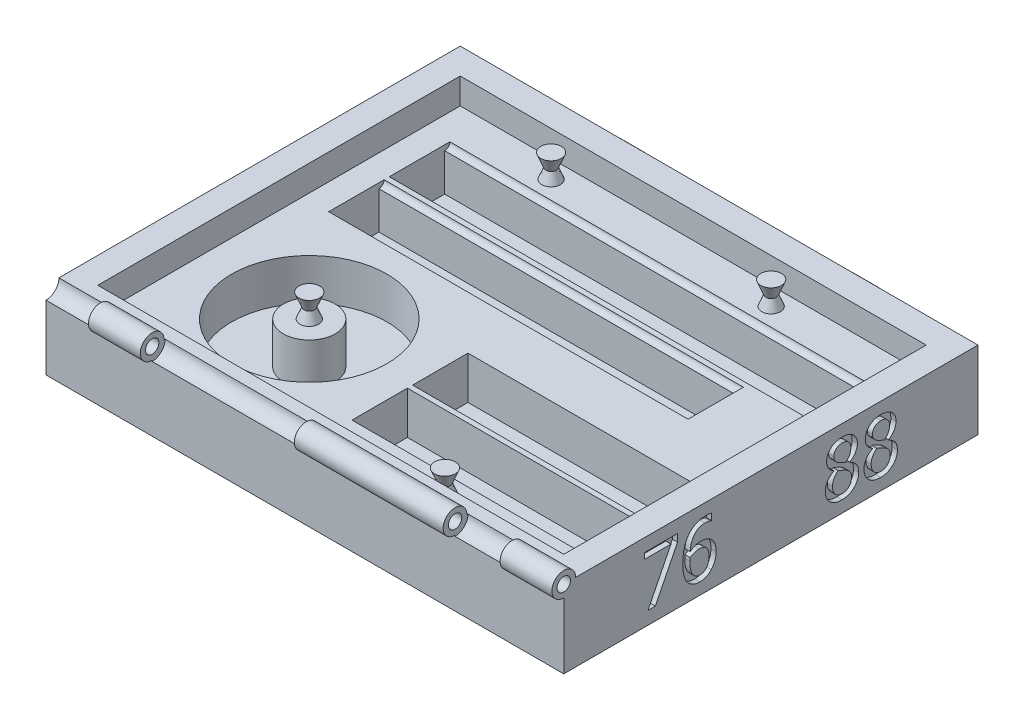
from build123d import *

# Parameters (mm, degrees)
BOSS_EXTRUDE1_DEPTH      = 177.8
SKETCH2_W                = 203.2
SKETCH2_H                = 27.178
SKETCH2_W_2              = 176.276
SKETCH2_H_2              = 24.638
SKETCH2_W_3              = 108.966
CUT_EXTRUDE1_DEPTH       = 12.7
SKETCH3_R                = 3.81
CUT_EXTRUDE2_DEPTH       = 108.966
SKETCH4_R                = 3.81
CUT_EXTRUDE3_DEPTH       = 203.2
SKETCH5_R                = 3.81
CUT_EXTRUDE4_DEPTH       = 176.276
SKETCH6_W                = 108.966
SKETCH6_H                = 24.638
CUT_EXTRUDE5_DEPTH       = 8.255
SKETCH9_W                = 3.81
SKETCH9_H                = 3.81
BOSS_EXTRUDE2_DEPTH      = 211.328
SKETCH10_R               = 2.54
CUT_EXTRUDE6_DEPTH       = 108.966
SKETCH11_R               = 2.54
CUT_EXTRUDE7_DEPTH       = 108.966
SKETCH12_R               = 2.54
CUT_EXTRUDE8_DEPTH       = 176.276
SKETCH13_R               = 2.54
CUT_EXTRUDE9_DEPTH       = 203.2
SKETCH14_W               = 108.966
SKETCH14_H               = 24.638
SKETCH14_W_2             = 176.276
SKETCH14_W_3             = 203.2
SKETCH14_H_2             = 27.178
CUT_EXTRUDE10_DEPTH      = 8.255
SKETCH15_W               = 12.7
SKETCH15_H               = 50.8
CUT_EXTRUDE11_DEPTH      = 44.45
CUT_EXTRUDE11_DEPTH_BACK = 379.73
SKETCH16_W               = 12.7
SKETCH16_H               = 50.8
BOSS_EXTRUDE3_DEPTH      = 254
SKETCH17_W               = 12.7
SKETCH17_H               = 50.8
BOSS_EXTRUDE4_DEPTH      = 254
SKETCH18_W               = 203.2
SKETCH18_H               = 12.7
CUT_EXTRUDE12_DEPTH      = 254
CUT_EXTRUDE13_DEPTH      = 2.54
SKETCH26_R               = 6.35
CUT_EXTRUDE14_DEPTH      = 309.626
SKETCH27_R               = 3.302
BOSS_EXTRUDE7_DEPTH      = 25.4
SKETCH29_R               = 5.842
SKETCH29_R_2             = 3.302
BOSS_EXTRUDE8_DEPTH      = 73.025
SKETCH31_R               = 5.842
SKETCH31_R_2             = 3.302
BOSS_EXTRUDE9_DEPTH      = 25.4
SKETCH35_R               = 38.1
CUT_EXTRUDE15_DEPTH      = 20.32
SKETCH36_R               = 12.7
BOSS_EXTRUDE11_DEPTH     = 20.32
SKETCH39_R               = 2.54
BOSS_EXTRUDE12_DEPTH     = 5.08
SKETCH47_R               = 2.54
BOSS_EXTRUDE13_DEPTH     = 5.08
SKETCH49_R               = 6.35
BOSS_EXTRUDE14_DEPTH     = 12.7
SKETCH51_R               = 6.35
BOSS_EXTRUDE15_DEPTH     = 12.7
SKETCH52_R               = 3.81
CUT_EXTRUDE16_DEPTH      = 137.16
FILLET1_R                = 5.08


with BuildPart() as part:
    # Sketch1 → Boss-Extrude1 (new body)
    with BuildSketch(Plane.XY):
        Polygon((0, 0), (254, 0), (254, 101.6), (241.3, 101.6), (241.3, 25.4), (12.7, 25.4), (12.7, 101.6), (0, 101.6), align=None)
    extrude(amount=BOSS_EXTRUDE1_DEPTH)

    # Sketch2 → Cut-Extrude1 (cut)
    with BuildSketch(Plane(origin=(0, 25.4, 0), x_dir=(1, 0, 0), z_dir=(0, 1, 0))):
        with Locations((127, -33.909)):
            Rectangle(SKETCH2_W, SKETCH2_H)
        with Locations((113.538, -64.897)):
            Rectangle(SKETCH2_W_2, SKETCH2_H_2)
        with Locations((174.117, -115.443)):
            Rectangle(SKETCH2_W_3, SKETCH2_H_2)
        with Locations((174.117, -145.161)):
            Rectangle(SKETCH2_W_3, SKETCH2_H_2)
    extrude(amount=-CUT_EXTRUDE1_DEPTH, mode=Mode.SUBTRACT)

    # Sketch3 → Cut-Extrude2 (cut)
    with BuildSketch(Plane.ZY.offset(-228.6)):
        with Locations((157.48, 25.4)):
            Circle(SKETCH3_R)
        with Locations((127.762, 25.4)):
            Circle(SKETCH3_R)
    extrude(amount=CUT_EXTRUDE2_DEPTH, mode=Mode.SUBTRACT)

    # Sketch4 → Cut-Extrude3 (cut)
    with BuildSketch(Plane.ZY.offset(-228.6)):
        with Locations((20.32, 25.4)):
            Circle(SKETCH4_R)
    extrude(amount=CUT_EXTRUDE3_DEPTH, mode=Mode.SUBTRACT)

    # Sketch5 → Cut-Extrude4 (cut)
    with BuildSketch(Plane.ZY.offset(-201.676)):
        with Locations((52.578, 25.4)):
            Circle(SKETCH5_R)
    extrude(amount=CUT_EXTRUDE4_DEPTH, mode=Mode.SUBTRACT)

    # Sketch6 → Cut-Extrude5 (cut)
    with BuildSketch(Plane(origin=(0, 12.7, 0), x_dir=(1, 0, 0), z_dir=(0, 1, 0))):
        with Locations((174.117, -145.161)):
            Rectangle(SKETCH6_W, SKETCH6_H)
    extrude(amount=-CUT_EXTRUDE5_DEPTH, mode=Mode.SUBTRACT)

    # Sketch9 → Boss-Extrude2 (add)
    with BuildSketch(Plane.ZY.offset(-228.6)):
        with Locations((159.385, 23.495)):
            Rectangle(SKETCH9_W, SKETCH9_H)
        with Locations((129.667, 23.495)):
            Rectangle(SKETCH9_W, SKETCH9_H)
        with Locations((50.673, 23.495)):
            Rectangle(SKETCH9_W, SKETCH9_H)
        with Locations((18.415, 23.495)):
            Rectangle(SKETCH9_W, SKETCH9_H)
    extrude(amount=BOSS_EXTRUDE2_DEPTH)

    # Sketch10 → Cut-Extrude6 (cut)
    with BuildSketch(Plane.ZY.offset(-228.6)):
        with Locations((157.48, 25.4)):
            Circle(SKETCH10_R)
    extrude(amount=CUT_EXTRUDE6_DEPTH, mode=Mode.SUBTRACT)

    # Sketch11 → Cut-Extrude7 (cut)
    with BuildSketch(Plane.ZY.offset(-228.6)):
        with Locations((127.762, 25.4)):
            Circle(SKETCH11_R)
    extrude(amount=CUT_EXTRUDE7_DEPTH, mode=Mode.SUBTRACT)

    # Sketch12 → Cut-Extrude8 (cut)
    with BuildSketch(Plane.ZY.offset(-201.676)):
        with Locations((52.578, 25.4)):
            Circle(SKETCH12_R)
    extrude(amount=CUT_EXTRUDE8_DEPTH, mode=Mode.SUBTRACT)

    # Sketch13 → Cut-Extrude9 (cut)
    with BuildSketch(Plane.ZY.offset(-228.6)):
        with Locations((20.32, 25.4)):
            Circle(SKETCH13_R)
    extrude(amount=CUT_EXTRUDE9_DEPTH, mode=Mode.SUBTRACT)

    # Sketch14 → Cut-Extrude10 (cut)
    with BuildSketch(Plane(origin=(0, 12.7, 0), x_dir=(1, 0, 0), z_dir=(0, 1, 0))):
        with Locations((174.117, -115.443)):
            Rectangle(SKETCH14_W, SKETCH14_H)
        with Locations((113.538, -64.897)):
            Rectangle(SKETCH14_W_2, SKETCH14_H)
        with Locations((127, -33.909)):
            Rectangle(SKETCH14_W_3, SKETCH14_H_2)
    extrude(amount=-CUT_EXTRUDE10_DEPTH, mode=Mode.SUBTRACT)

    # Sketch15 → Cut-Extrude11 (cut, two sides)
    with BuildSketch(Plane.XY.offset(177.8)) as cut_extrude11_sk:
        Polygon((12.7, 101.6), (12.7, 50.8), (241.3, 50.8), (241.3, 101.6), (254, 101.6), (254, 50.8), (294.328794801, 50.8), (294.328794801, 124.526428044), (-40.622984907, 124.526428044), (-40.622984907, 50.8), (0, 50.8), (0, 101.6), align=None)
        with Locations((6.35, 76.2)):
            Rectangle(SKETCH15_W, SKETCH15_H)
        with Locations((247.65, 76.2)):
            Rectangle(SKETCH15_W, SKETCH15_H)
    extrude(amount=CUT_EXTRUDE11_DEPTH, mode=Mode.SUBTRACT)
    extrude(cut_extrude11_sk.sketch, amount=-CUT_EXTRUDE11_DEPTH_BACK, mode=Mode.SUBTRACT)

    # Sketch16 → Boss-Extrude3 (add)
    with BuildSketch(Plane(origin=(254, 0, 0), x_dir=(0, 0, -1), z_dir=(1, 0, 0))):
        with Locations((-184.15, 25.4)):
            Rectangle(SKETCH16_W, SKETCH16_H)
    extrude(amount=-BOSS_EXTRUDE3_DEPTH)

    # Sketch17 → Boss-Extrude4 (add)
    with BuildSketch(Plane(origin=(254, 0, 0), x_dir=(0, 0, -1), z_dir=(1, 0, 0))):
        with Locations((6.35, 25.4)):
            Rectangle(SKETCH17_W, SKETCH17_H)
    extrude(amount=-BOSS_EXTRUDE4_DEPTH)

    # Sketch18 → Cut-Extrude12 (cut)
    with BuildSketch(Plane(origin=(254, 0, 0), x_dir=(0, 0, -1), z_dir=(1, 0, 0))):
        with Locations((-88.9, 44.45)):
            Rectangle(SKETCH18_W, SKETCH18_H)
    extrude(amount=-CUT_EXTRUDE12_DEPTH, mode=Mode.SUBTRACT)

    # Sketch25 → Cut-Extrude13 (cut)
    with BuildSketch(Plane(origin=(254, 0, 0), x_dir=(0, 0, -1), z_dir=(1, 0, 0))):
        Polygon((-134.716455696, 28.032436709), (-145.582792722, 6.35), (-149.184810127, 6.35), (-137.906526899, 28.856329114), (-150.792405063, 28.856329114), (-150.792405063, 31.75), (-134.716455696, 31.75), align=None)
        with BuildLine():
            add(Edge.make_bspline(
                [(-115.746835443, 14.62409019), (-115.754265987, 14.2971689), (-115.768836879, 13.656094076), (-115.892460294, 12.71225022), (-116.097444321, 11.809364679), (-116.380894986, 10.9501335), (-116.720897419, 10.142943973), (-117.134516856, 9.407605575), (-117.585891651, 8.728623869), (-117.94542237, 8.333616999), (-118.123061709, 8.138449367)],
                knots=[0, 0, 0, 0, 0.000980452, 0.001922613, 0.002850047, 0.003753998, 0.004633969, 0.005472752, 0.006282338, 0.007072998, 0.007072998, 0.007072998, 0.007072998], degree=3))
            add(Edge.make_bspline(
                [(-118.123061709, 8.138449367), (-118.313492965, 7.946720583), (-118.690582724, 7.567061475), (-119.316466328, 7.076861244), (-119.974186002, 6.656218321), (-120.663965914, 6.305547078), (-121.391827808, 6.040407142), (-122.154005881, 5.847491055), (-122.952283316, 5.730593007), (-123.498068702, 5.71491183), (-123.774762658, 5.706962025)],
                knots=[0, 0, 0, 0, 0.000810053, 0.001604057, 0.002378902, 0.003149517, 0.003920378, 0.004697743, 0.005504831, 0.006334721, 0.006334721, 0.006334721, 0.006334721], degree=3))
            add(Edge.make_bspline(
                [(-123.774762658, 5.706962025), (-124.054846776, 5.712776355), (-124.602242402, 5.724139863), (-125.404111023, 5.841004275), (-126.168078478, 6.017056739), (-126.892880073, 6.275237829), (-127.572508988, 6.610199113), (-128.216589464, 7.008340862), (-128.818572726, 7.482094043), (-129.179030779, 7.848049207), (-129.361155063, 8.032950949)],
                knots=[0, 0, 0, 0, 0.0008397, 0.001641108, 0.00242584, 0.003188555, 0.00394347, 0.00469485, 0.005456688, 0.006234718, 0.006234718, 0.006234718, 0.006234718], degree=3))
            add(Edge.make_bspline(
                [(-129.361155063, 8.032950949), (-129.573854928, 8.280724977), (-130.010793532, 8.789714663), (-130.554498534, 9.675944215), (-131.025026034, 10.675272197), (-131.361321511, 11.585407386), (-131.582854659, 12.375147016), (-131.733331863, 13.010356591), (-131.866602572, 13.678161633), (-131.962641653, 14.381626275), (-132.043769901, 15.116977219), (-132.104274503, 15.885884522), (-132.139865466, 16.690174248), (-132.14280382, 17.238069973), (-132.144303797, 17.517761076)],
                knots=[0, 0, 0, 0, 0.000978404, 0.002009885, 0.003106453, 0.004288921, 0.004915499, 0.005566184, 0.006246988, 0.006957452, 0.007695308, 0.0084663, 0.009270866, 0.01010989, 0.01010989, 0.01010989, 0.01010989], degree=3))
            add(Edge.make_bspline(
                [(-132.144303797, 17.517761076), (-132.138186193, 18.062331069), (-132.126252123, 19.124664563), (-131.986882078, 20.677021482), (-131.789888669, 22.150324887), (-131.492837148, 23.542673457), (-131.107694662, 24.849971548), (-130.635700427, 26.073962328), (-130.070741737, 27.211486195), (-129.615796388, 27.909189771), (-129.391297468, 28.253481013)],
                knots=[0, 0, 0, 0, 0.001633208, 0.003186022, 0.004672317, 0.006090194, 0.007452442, 0.008756679, 0.010021563, 0.011253802, 0.011253802, 0.011253802, 0.011253802], degree=3))
            add(Edge.make_bspline(
                [(-129.391297468, 28.253481013), (-129.1542525, 28.566213928), (-128.681637737, 29.189733566), (-127.840259024, 30.011906782), (-126.894698179, 30.71700161), (-126.039448776, 31.221889415), (-125.308268092, 31.561200797), (-124.733254546, 31.781106532), (-124.138836714, 31.974060725), (-123.523113064, 32.129548918), (-122.88470213, 32.243698826), (-122.227448333, 32.327682379), (-121.548663564, 32.387398883), (-121.088871693, 32.391141981), (-120.855973101, 32.393037975)],
                knots=[0, 0, 0, 0, 0.00117608, 0.00234484, 0.003514367, 0.004707703, 0.005316819, 0.005930702, 0.006553483, 0.007190725, 0.007834175, 0.008497803, 0.009178254, 0.009876716, 0.009876716, 0.009876716, 0.009876716], degree=3))
            add(Edge.make_bspline(
                [(-120.855973101, 32.393037975), (-120.582793509, 32.390267957), (-120.057355247, 32.384940059), (-119.303274908, 32.314390604), (-118.61673876, 32.224330971), (-118.195650693, 32.099926657), (-117.997468354, 32.041376582)],
                knots=[0, 0, 0, 0, 0.000819115, 0.0015755, 0.00227179, 0.002890852, 0.002890852, 0.002890852, 0.002890852], degree=3))
            Line((-117.997468354, 32.041376582), (-117.997468354, 28.856329114))
            Line((-117.997468354, 28.856329114), (-118.14818038, 28.856329114))
            add(Edge.make_bspline(
                [(-118.14818038, 28.856329114), (-118.231104083, 28.898406425), (-118.409577279, 28.988967652), (-118.714311444, 29.092331174), (-119.062026789, 29.207905049), (-119.603685251, 29.337778558), (-120.342366078, 29.4746922), (-120.953972965, 29.490997402), (-121.267919304, 29.499367089)],
                knots=[0, 0, 0, 0, 0.000278625, 0.000599672, 0.000963503, 0.001377771, 0.002269749, 0.00321053, 0.00321053, 0.00321053, 0.00321053], degree=3))
            add(Edge.make_bspline(
                [(-121.267919304, 29.499367089), (-121.521128554, 29.492581233), (-122.016206176, 29.479313451), (-122.738211116, 29.376576435), (-123.423940747, 29.210971352), (-124.074115504, 28.976020514), (-124.683214738, 28.665955908), (-125.258286079, 28.297143573), (-125.792775979, 27.855666381), (-126.291012284, 27.348267155), (-126.741928421, 26.771596588), (-127.154671117, 26.136315479), (-127.502418595, 25.426693133), (-127.809103077, 24.655596168), (-128.069423296, 23.820966296), (-128.27978111, 22.921077794), (-128.441062788, 21.956107608), (-128.504586998, 21.287742324), (-128.537262658, 20.943947785)],
                knots=[0, 0, 0, 0, 0.000759399, 0.001484785, 0.002182957, 0.002872692, 0.003553441, 0.004229278, 0.004918189, 0.005628688, 0.006358358, 0.007110863, 0.007897201, 0.00872467, 0.009598569, 0.010517349, 0.011495211, 0.01253099, 0.01253099, 0.01253099, 0.01253099], degree=3))
            add(Edge.make_bspline(
                [(-128.537262658, 20.943947785), (-128.338336548, 21.084380764), (-127.947394038, 21.360368775), (-127.33317718, 21.715905478), (-126.718213325, 22.030152515), (-126.088042864, 22.288137668), (-125.43991704, 22.499774297), (-124.761183472, 22.642502508), (-124.053350544, 22.729750013), (-123.57239489, 22.741492791), (-123.327650316, 22.747468354)],
                knots=[0, 0, 0, 0, 0.000730154, 0.001434947, 0.002126929, 0.002800503, 0.003475723, 0.004169399, 0.004877888, 0.005611972, 0.005611972, 0.005611972, 0.005611972], degree=3))
            add(Edge.make_bspline(
                [(-123.327650316, 22.747468354), (-123.09143392, 22.743375783), (-122.633401495, 22.735440134), (-121.968603673, 22.681127486), (-121.348822059, 22.586674888), (-120.762696937, 22.45030794), (-120.191772633, 22.256402114), (-119.622744027, 21.985381495), (-119.039972838, 21.641933616), (-118.664840253, 21.364547264), (-118.469699367, 21.220253165)],
                knots=[0, 0, 0, 0, 0.000708631, 0.001374063, 0.001999311, 0.00258786, 0.003177267, 0.003804288, 0.00447546, 0.005203121, 0.005203121, 0.005203121, 0.005203121], degree=3))
            add(Edge.make_bspline(
                [(-118.469699367, 21.220253165), (-118.250067065, 21.034913779), (-117.813340127, 20.666376447), (-117.252125302, 20.014387576), (-116.782853864, 19.289376131), (-116.399505479, 18.494071784), (-116.102240993, 17.627183966), (-115.89462462, 16.688600517), (-115.766902881, 15.679257469), (-115.753658329, 14.982844791), (-115.746835443, 14.62409019)],
                knots=[0, 0, 0, 0, 0.000861098, 0.001712247, 0.002569202, 0.00344548, 0.004354235, 0.005312175, 0.006324741, 0.007400571, 0.007400571, 0.007400571, 0.007400571], degree=3))
        make_face()
        with BuildLine():
            add(Edge.make_bspline(
                [(-119.283544304, 14.493473101), (-119.28770176, 14.746582373), (-119.29567903, 15.232245068), (-119.374347134, 15.928840027), (-119.487628819, 16.563481351), (-119.666311671, 17.136638998), (-119.901061685, 17.657698353), (-120.191738744, 18.138855907), (-120.55354926, 18.576005717), (-120.834276471, 18.830566893), (-120.976542722, 18.959572785)],
                knots=[0, 0, 0, 0, 0.000759, 0.001456358, 0.002100729, 0.002690221, 0.003252341, 0.003811512, 0.004371766, 0.004947416, 0.004947416, 0.004947416, 0.004947416], degree=3))
            add(Edge.make_bspline(
                [(-120.976542722, 18.959572785), (-121.084982404, 19.046256587), (-121.300796817, 19.218772898), (-121.659825204, 19.423846115), (-122.041512213, 19.582418504), (-122.578849017, 19.723328576), (-123.276351103, 19.832420961), (-123.841306093, 19.8466277), (-124.126424051, 19.853797468)],
                knots=[0, 0, 0, 0, 0.00041597, 0.000827855, 0.001235552, 0.001652371, 0.002491515, 0.003346495, 0.003346495, 0.003346495, 0.003346495], degree=3))
            add(Edge.make_bspline(
                [(-124.126424051, 19.853797468), (-124.319264104, 19.850944618), (-124.702923814, 19.845268807), (-125.27154516, 19.768553307), (-125.834049004, 19.661896106), (-126.386354345, 19.496539894), (-126.934336675, 19.297431808), (-127.474725145, 19.052102448), (-128.013202414, 18.773095955), (-128.361127788, 18.55670059), (-128.537262658, 18.447151899)],
                knots=[0, 0, 0, 0, 0.000578079, 0.001150101, 0.001718583, 0.002294102, 0.002877396, 0.003466545, 0.004073254, 0.004695305, 0.004695305, 0.004695305, 0.004695305], degree=3))
            add(Edge.make_bspline(
                [(-128.537262658, 18.447151899), (-128.547351946, 18.323245079), (-128.567249292, 18.078885215), (-128.59713455, 17.702422071), (-128.603362653, 17.28667086), (-128.606091275, 16.991931557), (-128.607594937, 16.829509494)],
                knots=[0, 0, 0, 0, 0.000372976, 0.000735556, 0.001132558, 0.001619887, 0.001619887, 0.001619887, 0.001619887], degree=3))
            add(Edge.make_bspline(
                [(-128.607594937, 16.829509494), (-128.602986154, 16.40729016), (-128.594212471, 15.60351653), (-128.497530121, 14.462580742), (-128.349624808, 13.44803037), (-128.127300426, 12.559311147), (-127.853674457, 11.789456171), (-127.557231931, 11.117208569), (-127.234183633, 10.540070719), (-126.972421858, 10.215308924), (-126.849287975, 10.062539557)],
                knots=[0, 0, 0, 0, 0.00126634, 0.002410715, 0.003432425, 0.004338941, 0.005154041, 0.0058804, 0.006542162, 0.00712996, 0.00712996, 0.00712996, 0.00712996], degree=3))
            add(Edge.make_bspline(
                [(-126.849287975, 10.062539557), (-126.730517874, 9.936898078), (-126.501692653, 9.6948343), (-126.141096206, 9.371887319), (-125.765576473, 9.122637802), (-125.389641543, 8.91772632), (-124.995503564, 8.781742418), (-124.593664222, 8.672110052), (-124.173428746, 8.612284902), (-123.888801282, 8.604550735), (-123.744620253, 8.600632911)],
                knots=[0, 0, 0, 0, 0.000518687, 0.000999314, 0.001447976, 0.001868202, 0.002279811, 0.002695326, 0.003116631, 0.003549139, 0.003549139, 0.003549139, 0.003549139], degree=3))
            add(Edge.make_bspline(
                [(-123.744620253, 8.600632911), (-123.582000512, 8.606171072), (-123.26381781, 8.617007068), (-122.798111602, 8.680946947), (-122.356277774, 8.79757891), (-121.940646725, 8.96336271), (-121.547864545, 9.174204393), (-121.173799155, 9.422099327), (-120.832097469, 9.730361534), (-120.509289898, 10.075784926), (-120.216733142, 10.468379543), (-119.964798243, 10.908933719), (-119.754534219, 11.396742414), (-119.577584221, 11.927182538), (-119.451913302, 12.507443043), (-119.348009361, 13.127134644), (-119.295992166, 13.795969508), (-119.287789201, 14.255614513), (-119.283544304, 14.493473101)],
                knots=[0, 0, 0, 0, 0.000487949, 0.000954724, 0.001406804, 0.001855523, 0.00229377, 0.002742432, 0.003198015, 0.003670807, 0.004159118, 0.004663222, 0.005189636, 0.00575043, 0.006337842, 0.006968836, 0.007634267, 0.00834792, 0.00834792, 0.00834792, 0.00834792], degree=3))
        make_face(mode=Mode.SUBTRACT)
        with BuildLine():
            add(Edge.make_bspline(
                [(-54.015189873, 5.706962025), (-54.321958159, 5.713371236), (-54.922309696, 5.725914185), (-55.801416484, 5.834333035), (-56.637448002, 6.008362812), (-57.429112988, 6.253575941), (-58.168718269, 6.57101731), (-58.854831446, 6.949779103), (-59.491383657, 7.383637341), (-59.863497775, 7.729968762), (-60.04869462, 7.902333861)],
                knots=[0, 0, 0, 0, 0.000920016, 0.001800489, 0.002652763, 0.003479011, 0.004282463, 0.005062696, 0.00582779, 0.006585841, 0.006585841, 0.006585841, 0.006585841], degree=3))
            add(Edge.make_bspline(
                [(-60.04869462, 7.902333861), (-60.22083116, 8.077479587), (-60.562691756, 8.425316382), (-60.993627271, 9.020308779), (-61.376008863, 9.651701172), (-61.677918702, 10.337711261), (-61.919582456, 11.05385458), (-62.090234672, 11.795942359), (-62.192848772, 12.558124119), (-62.206855844, 13.073116564), (-62.213924051, 13.332990506)],
                knots=[0, 0, 0, 0, 0.00073575, 0.001461188, 0.002197829, 0.002946635, 0.00370442, 0.004462405, 0.005227614, 0.006007087, 0.006007087, 0.006007087, 0.006007087], degree=3))
            add(Edge.make_bspline(
                [(-62.213924051, 13.332990506), (-62.199856497, 13.672207258), (-62.172027341, 14.343263238), (-61.96592865, 15.329388294), (-61.620112655, 16.270288807), (-61.224264143, 17.01399799), (-60.836289251, 17.570324229), (-60.519861534, 17.976520589), (-60.167802245, 18.356851787), (-59.785510105, 18.715217066), (-59.368904884, 19.04609423), (-58.928294415, 19.365482613), (-58.451567513, 19.655196983), (-58.117300319, 19.82730902), (-57.948773734, 19.914082278)],
                knots=[0, 0, 0, 0, 0.001017229, 0.002012334, 0.003007236, 0.004016419, 0.004529234, 0.005040792, 0.005559868, 0.006082361, 0.006611167, 0.007154869, 0.00771404, 0.00828261, 0.00828261, 0.00828261, 0.00828261], degree=3))
            Line((-57.948773734, 19.914082278), (-57.948773734, 20.014556962))
            add(Edge.make_bspline(
                [(-57.948773734, 20.014556962), (-58.240875684, 20.196222946), (-58.800354656, 20.544177823), (-59.543644637, 21.140303936), (-60.178208727, 21.748901036), (-60.696736038, 22.398402624), (-61.09245452, 23.109126352), (-61.375312602, 23.891870628), (-61.541950667, 24.756651267), (-61.561008539, 25.359058819), (-61.570886076, 25.671281646)],
                knots=[0, 0, 0, 0, 0.001031127, 0.001974974, 0.002852461, 0.003664521, 0.004458414, 0.005281632, 0.006151609, 0.007087656, 0.007087656, 0.007087656, 0.007087656], degree=3))
            add(Edge.make_bspline(
                [(-61.570886076, 25.671281646), (-61.56419003, 25.907807022), (-61.551067792, 26.371325739), (-61.445854165, 27.050938609), (-61.284808272, 27.701591694), (-61.041070995, 28.31763825), (-60.749944236, 28.912164934), (-60.368477529, 29.463317232), (-59.93918881, 29.99684018), (-59.433863196, 30.482868382), (-58.889003259, 30.934813809), (-58.294031348, 31.323617305), (-57.666555091, 31.654374324), (-57.003763703, 31.930681348), (-56.302954935, 32.131805353), (-55.569610715, 32.285067779), (-54.799522244, 32.376352623), (-54.273317496, 32.387405158), (-54.005142405, 32.393037975)],
                knots=[0, 0, 0, 0, 0.000709219, 0.001389856, 0.002058787, 0.002715591, 0.003373872, 0.004039891, 0.004721733, 0.005425127, 0.006139134, 0.00684278, 0.007552905, 0.008264735, 0.008992778, 0.009736647, 0.010510579, 0.011314942, 0.011314942, 0.011314942, 0.011314942], degree=3))
            add(Edge.make_bspline(
                [(-54.005142405, 32.393037975), (-53.726920582, 32.387243042), (-53.184195876, 32.37593892), (-52.391589465, 32.288086848), (-51.639485086, 32.150466218), (-50.930252109, 31.948685925), (-50.261233194, 31.692570437), (-49.636955774, 31.375380498), (-49.055550493, 31.0005149), (-48.518823997, 30.576240296), (-48.039420135, 30.103268612), (-47.611081286, 29.602170047), (-47.260131109, 29.058528506), (-46.96559941, 28.489393112), (-46.737107253, 27.886006607), (-46.579965746, 27.249967217), (-46.47313839, 26.584167444), (-46.464093233, 26.12887229), (-46.459493671, 25.897349684)],
                knots=[0, 0, 0, 0, 0.000834484, 0.001627821, 0.00238946, 0.003125758, 0.003836665, 0.004535398, 0.005222401, 0.005908909, 0.006583887, 0.007239979, 0.00788233, 0.008520423, 0.009159564, 0.00981265, 0.010483351, 0.011177281, 0.011177281, 0.011177281, 0.011177281], degree=3))
            add(Edge.make_bspline(
                [(-46.459493671, 25.897349684), (-46.471298092, 25.611766462), (-46.495071009, 25.03663058), (-46.684969899, 24.177187822), (-46.997029358, 23.326175472), (-47.413336778, 22.486603344), (-47.94539906, 21.696164443), (-48.594872465, 20.987026914), (-49.350241779, 20.367714365), (-49.922260789, 20.04334321), (-50.212223101, 19.878916139)],
                knots=[0, 0, 0, 0, 0.00085616, 0.00172422, 0.002626844, 0.00357045, 0.004529089, 0.005474966, 0.006446302, 0.007444863, 0.007444863, 0.007444863, 0.007444863], degree=3))
            Line((-50.212223101, 19.878916139), (-50.212223101, 19.778441456))
            add(Edge.make_bspline(
                [(-50.212223101, 19.778441456), (-49.870275603, 19.600761474), (-49.210413098, 19.257889078), (-48.313160928, 18.654979264), (-47.552478327, 17.98740828), (-47.017085382, 17.379071381), (-46.663886372, 16.857519664), (-46.435207062, 16.442752378), (-46.248443627, 15.999804524), (-46.081495731, 15.534002862), (-45.965470704, 15.037923023), (-45.880934789, 14.515788715), (-45.821935383, 13.968994714), (-45.818306526, 13.59438529), (-45.816455696, 13.403322785)],
                knots=[0, 0, 0, 0, 0.001155503, 0.002229795, 0.003233587, 0.004184454, 0.004651229, 0.005121129, 0.005602674, 0.006092018, 0.006603774, 0.007128219, 0.007678587, 0.008251491, 0.008251491, 0.008251491, 0.008251491], degree=3))
            add(Edge.make_bspline(
                [(-45.816455696, 13.403322785), (-45.822661168, 13.135025968), (-45.834855925, 12.607779314), (-45.947385362, 11.834454729), (-46.137143987, 11.097719401), (-46.383783072, 10.387910027), (-46.72227984, 9.717944463), (-47.123569405, 9.075510151), (-47.605071125, 8.471845403), (-48.150715562, 7.90756508), (-48.748627305, 7.390842473), (-49.395054647, 6.945406892), (-50.07141913, 6.557559772), (-50.789353158, 6.245760939), (-51.545255066, 6.004109092), (-52.338135915, 5.836006367), (-53.164771988, 5.725868589), (-53.72847603, 5.713336272), (-54.015189873, 5.706962025)],
                knots=[0, 0, 0, 0, 0.000804566, 0.001581103, 0.002337755, 0.003084587, 0.003830488, 0.004584534, 0.005353428, 0.00614217, 0.006936635, 0.007719839, 0.008493755, 0.009272158, 0.01006336, 0.010870369, 0.011700989, 0.012560767, 0.012560767, 0.012560767, 0.012560767], degree=3))
        make_face()
        with BuildLine():
            add(Edge.make_bspline(
                [(-49.674683544, 25.832041139), (-49.676511279, 25.971275362), (-49.680116102, 26.245885529), (-49.740463122, 26.646847224), (-49.82101163, 27.032429596), (-49.951394828, 27.395360752), (-50.106390128, 27.744586257), (-50.296729743, 28.078677873), (-50.530447209, 28.388362359), (-50.790915726, 28.681015411), (-51.083085729, 28.947840659), (-51.403060687, 29.184863068), (-51.753599417, 29.380824783), (-52.128633649, 29.543592239), (-52.531588163, 29.667413933), (-52.96160629, 29.759818111), (-53.419666469, 29.807092859), (-53.733771434, 29.816214837), (-53.894620253, 29.820886076)],
                knots=[0, 0, 0, 0, 0.000417242, 0.000822922, 0.001214161, 0.001597054, 0.001977069, 0.002359665, 0.002747503, 0.003138838, 0.003533545, 0.00393245, 0.004330627, 0.004735653, 0.005156719, 0.005593206, 0.006053118, 0.006535814, 0.006535814, 0.006535814, 0.006535814], degree=3))
            add(Edge.make_bspline(
                [(-53.894620253, 29.820886076), (-54.042140322, 29.818503173), (-54.333050776, 29.813804073), (-54.75795121, 29.761612255), (-55.162995053, 29.681926589), (-55.546161096, 29.570858548), (-55.910990247, 29.431279852), (-56.252800342, 29.253297602), (-56.577543926, 29.047230667), (-56.876365879, 28.807012137), (-57.147809239, 28.541488568), (-57.386575935, 28.252805016), (-57.590297249, 27.940583065), (-57.748003324, 27.600058941), (-57.88188993, 27.243727687), (-57.972299254, 26.862418366), (-58.020454719, 26.4595811), (-58.029539209, 26.183823538), (-58.034177215, 26.043037975)],
                knots=[0, 0, 0, 0, 0.000442345, 0.000872308, 0.001282166, 0.001679644, 0.002067742, 0.002451951, 0.002833788, 0.003219799, 0.003599913, 0.003971058, 0.004341727, 0.004714737, 0.005094586, 0.005482065, 0.005887092, 0.006309563, 0.006309563, 0.006309563, 0.006309563], degree=3))
            add(Edge.make_bspline(
                [(-58.034177215, 26.043037975), (-58.028530829, 25.839828374), (-58.017658448, 25.448538745), (-57.902730864, 24.884873626), (-57.719349807, 24.370367344), (-57.455915864, 23.901285024), (-57.115030689, 23.474846347), (-56.705716573, 23.071292998), (-56.2179626, 22.694713729), (-55.859222395, 22.468175556), (-55.673022152, 22.350593354)],
                knots=[0, 0, 0, 0, 0.000608888, 0.001172443, 0.001717535, 0.002241595, 0.002778266, 0.0033502, 0.003962209, 0.004622673, 0.004622673, 0.004622673, 0.004622673], degree=3))
            add(Edge.make_bspline(
                [(-55.673022152, 22.350593354), (-55.576248914, 22.296346782), (-55.361214541, 22.175808521), (-54.998422608, 21.993367225), (-54.57161355, 21.776961124), (-53.93554213, 21.456097251), (-53.136416266, 21.087851097), (-52.482834706, 20.849628729), (-52.176503165, 20.737974684)],
                knots=[0, 0, 0, 0, 0.000332782, 0.000739456, 0.001218005, 0.001768442, 0.002876879, 0.003854702, 0.003854702, 0.003854702, 0.003854702], degree=3))
            add(Edge.make_bspline(
                [(-52.176503165, 20.737974684), (-51.947478445, 20.923791473), (-51.510347802, 21.278452807), (-50.95600761, 21.866812966), (-50.506535851, 22.454462546), (-50.18595317, 23.069855165), (-49.949957182, 23.705192054), (-49.794546924, 24.377606344), (-49.687688156, 25.09013777), (-49.679093905, 25.580433376), (-49.674683544, 25.832041139)],
                knots=[0, 0, 0, 0, 0.000883835, 0.001686941, 0.002419408, 0.003095842, 0.003760268, 0.004447492, 0.005162928, 0.005917091, 0.005917091, 0.005917091, 0.005917091], degree=3))
        make_face(mode=Mode.SUBTRACT)
        with BuildLine():
            add(Edge.make_bspline(
                [(-49.353164557, 13.086827532), (-49.358298351, 13.335200051), (-49.368108871, 13.809832137), (-49.485077508, 14.478611609), (-49.668043801, 15.070958181), (-49.943817059, 15.596766776), (-50.34065523, 16.076766947), (-50.859292656, 16.547342326), (-51.5196765, 17.018771361), (-52.019671709, 17.307899576), (-52.287025316, 17.4625)],
                knots=[0, 0, 0, 0, 0.000744344, 0.001422418, 0.002029313, 0.002597883, 0.003191025, 0.003887858, 0.004693788, 0.005619969, 0.005619969, 0.005619969, 0.005619969], degree=3))
            add(Edge.make_bspline(
                [(-52.287025316, 17.4625), (-52.388795196, 17.518471129), (-52.606721148, 17.638325467), (-52.961069211, 17.813140155), (-53.366912915, 17.987825107), (-53.988483233, 18.240941801), (-54.85454308, 18.592287458), (-55.563109445, 18.897835268), (-55.939280063, 19.060047468)],
                knots=[0, 0, 0, 0, 0.000348417, 0.000746086, 0.001184765, 0.001673618, 0.002759535, 0.003988462, 0.003988462, 0.003988462, 0.003988462], degree=3))
            add(Edge.make_bspline(
                [(-55.939280063, 19.060047468), (-56.152962022, 18.899428028), (-56.574165185, 18.582820035), (-57.124384511, 18.023070188), (-57.595306763, 17.40988451), (-57.990075615, 16.744985731), (-58.296657498, 16.026610801), (-58.519669367, 15.261422988), (-58.651461829, 14.44611166), (-58.668492334, 13.886087312), (-58.67721519, 13.599248418)],
                knots=[0, 0, 0, 0, 0.000801061, 0.001579027, 0.002345702, 0.003115957, 0.003892363, 0.004682496, 0.005501796, 0.006362044, 0.006362044, 0.006362044, 0.006362044], degree=3))
            add(Edge.make_bspline(
                [(-58.67721519, 13.599248418), (-58.673897014, 13.411492046), (-58.667358127, 13.041494169), (-58.59978828, 12.500519674), (-58.4948329, 11.984531871), (-58.348915273, 11.492815008), (-58.158961347, 11.026488823), (-57.923808428, 10.585893645), (-57.655185007, 10.166346358), (-57.337043433, 9.783345615), (-56.993464451, 9.430395051), (-56.62034126, 9.12602781), (-56.23215913, 8.858551847), (-55.815470787, 8.647945494), (-55.379646603, 8.481357601), (-54.920880201, 8.366007034), (-54.442810261, 8.294053958), (-54.115921931, 8.284146399), (-53.949881329, 8.279113924)],
                knots=[0, 0, 0, 0, 0.000563017, 0.001109497, 0.001632665, 0.002141279, 0.002645983, 0.003140381, 0.003637832, 0.004137637, 0.004631422, 0.005113203, 0.005579978, 0.006042816, 0.006510266, 0.006976933, 0.007459343, 0.007957326, 0.007957326, 0.007957326, 0.007957326], degree=3))
            add(Edge.make_bspline(
                [(-53.949881329, 8.279113924), (-53.780562246, 8.282792275), (-53.449180812, 8.28999133), (-52.96488174, 8.351628354), (-52.505531289, 8.451448023), (-52.072352601, 8.591381091), (-51.664263332, 8.774384613), (-51.28480196, 9.000400637), (-50.928745162, 9.263818661), (-50.603222481, 9.56629288), (-50.305593167, 9.899568847), (-50.054016757, 10.271972291), (-49.837347896, 10.670803476), (-49.655184479, 11.096947476), (-49.519732579, 11.554141411), (-49.426703197, 12.038925375), (-49.363551208, 12.552666828), (-49.35668509, 12.905774909), (-49.353164557, 13.086827532)],
                knots=[0, 0, 0, 0, 0.000507795, 0.000993827, 0.001461897, 0.001916261, 0.002356977, 0.00280069, 0.003238764, 0.003683159, 0.004131652, 0.00457616, 0.005028017, 0.005491754, 0.005963798, 0.006455431, 0.006971386, 0.007514322, 0.007514322, 0.007514322, 0.007514322], degree=3))
        make_face(mode=Mode.SUBTRACT)
        with BuildLine():
            add(Edge.make_bspline(
                [(-35.04556962, 5.706962025), (-35.352337905, 5.713371236), (-35.952689443, 5.725914185), (-36.831796231, 5.834333035), (-37.667827748, 6.008362812), (-38.459492735, 6.253575941), (-39.199098015, 6.57101731), (-39.885211193, 6.949779103), (-40.521763404, 7.383637341), (-40.893877521, 7.729968762), (-41.079074367, 7.902333861)],
                knots=[0, 0, 0, 0, 0.000920016, 0.001800489, 0.002652763, 0.003479011, 0.004282463, 0.005062696, 0.00582779, 0.006585841, 0.006585841, 0.006585841, 0.006585841], degree=3))
            add(Edge.make_bspline(
                [(-41.079074367, 7.902333861), (-41.251210907, 8.077479587), (-41.593071503, 8.425316382), (-42.024007018, 9.020308779), (-42.40638861, 9.651701172), (-42.708298449, 10.337711261), (-42.949962203, 11.05385458), (-43.120614419, 11.795942359), (-43.223228519, 12.558124119), (-43.237235591, 13.073116564), (-43.244303797, 13.332990506)],
                knots=[0, 0, 0, 0, 0.00073575, 0.001461188, 0.002197829, 0.002946635, 0.00370442, 0.004462405, 0.005227614, 0.006007087, 0.006007087, 0.006007087, 0.006007087], degree=3))
            add(Edge.make_bspline(
                [(-43.244303797, 13.332990506), (-43.230236244, 13.672207258), (-43.202407088, 14.343263238), (-42.996308396, 15.329388294), (-42.650492401, 16.270288807), (-42.25464389, 17.01399799), (-41.866668998, 17.570324229), (-41.550241281, 17.976520589), (-41.198181992, 18.356851787), (-40.815889852, 18.715217066), (-40.399284631, 19.04609423), (-39.958674162, 19.365482613), (-39.48194726, 19.655196983), (-39.147680065, 19.82730902), (-38.979153481, 19.914082278)],
                knots=[0, 0, 0, 0, 0.001017229, 0.002012334, 0.003007236, 0.004016419, 0.004529234, 0.005040792, 0.005559868, 0.006082361, 0.006611167, 0.007154869, 0.00771404, 0.00828261, 0.00828261, 0.00828261, 0.00828261], degree=3))
            Line((-38.979153481, 19.914082278), (-38.979153481, 20.014556962))
            add(Edge.make_bspline(
                [(-38.979153481, 20.014556962), (-39.27125543, 20.196222946), (-39.830734403, 20.544177823), (-40.574024384, 21.140303936), (-41.208588474, 21.748901036), (-41.727115785, 22.398402624), (-42.122834267, 23.109126352), (-42.405692349, 23.891870628), (-42.572330414, 24.756651267), (-42.591388286, 25.359058819), (-42.601265823, 25.671281646)],
                knots=[0, 0, 0, 0, 0.001031127, 0.001974974, 0.002852461, 0.003664521, 0.004458414, 0.005281632, 0.006151609, 0.007087656, 0.007087656, 0.007087656, 0.007087656], degree=3))
            add(Edge.make_bspline(
                [(-42.601265823, 25.671281646), (-42.594569777, 25.907807022), (-42.581447539, 26.371325739), (-42.476233912, 27.050938609), (-42.315188018, 27.701591694), (-42.071450742, 28.31763825), (-41.780323983, 28.912164934), (-41.398857276, 29.463317232), (-40.969568557, 29.99684018), (-40.464242943, 30.482868382), (-39.919383005, 30.934813809), (-39.324411095, 31.323617305), (-38.696934838, 31.654374324), (-38.03414345, 31.930681348), (-37.333334682, 32.131805353), (-36.599990462, 32.285067779), (-35.829901991, 32.376352623), (-35.303697243, 32.387405158), (-35.035522152, 32.393037975)],
                knots=[0, 0, 0, 0, 0.000709219, 0.001389856, 0.002058787, 0.002715591, 0.003373872, 0.004039891, 0.004721733, 0.005425127, 0.006139134, 0.00684278, 0.007552905, 0.008264735, 0.008992778, 0.009736647, 0.010510579, 0.011314942, 0.011314942, 0.011314942, 0.011314942], degree=3))
            add(Edge.make_bspline(
                [(-35.035522152, 32.393037975), (-34.757300329, 32.387243042), (-34.214575623, 32.37593892), (-33.421969212, 32.288086848), (-32.669864833, 32.150466218), (-31.960631856, 31.948685925), (-31.291612941, 31.692570437), (-30.667335521, 31.375380498), (-30.08593024, 31.0005149), (-29.549203743, 30.576240296), (-29.069799882, 30.103268612), (-28.641461033, 29.602170047), (-28.290510856, 29.058528506), (-27.995979157, 28.489393112), (-27.767486999, 27.886006607), (-27.610345493, 27.249967217), (-27.503518137, 26.584167444), (-27.49447298, 26.12887229), (-27.489873418, 25.897349684)],
                knots=[0, 0, 0, 0, 0.000834484, 0.001627821, 0.00238946, 0.003125758, 0.003836665, 0.004535398, 0.005222401, 0.005908909, 0.006583887, 0.007239979, 0.00788233, 0.008520423, 0.009159564, 0.00981265, 0.010483351, 0.011177281, 0.011177281, 0.011177281, 0.011177281], degree=3))
            add(Edge.make_bspline(
                [(-27.489873418, 25.897349684), (-27.501677839, 25.611766462), (-27.525450756, 25.03663058), (-27.715349645, 24.177187822), (-28.027409105, 23.326175472), (-28.443716525, 22.486603344), (-28.975778807, 21.696164443), (-29.625252212, 20.987026914), (-30.380621525, 20.367714365), (-30.952640536, 20.04334321), (-31.242602848, 19.878916139)],
                knots=[0, 0, 0, 0, 0.00085616, 0.00172422, 0.002626844, 0.00357045, 0.004529089, 0.005474966, 0.006446302, 0.007444863, 0.007444863, 0.007444863, 0.007444863], degree=3))
            Line((-31.242602848, 19.878916139), (-31.242602848, 19.778441456))
            add(Edge.make_bspline(
                [(-31.242602848, 19.778441456), (-30.90065535, 19.600761474), (-30.240792844, 19.257889078), (-29.343540674, 18.654979264), (-28.582858074, 17.98740828), (-28.047465129, 17.379071381), (-27.694266119, 16.857519664), (-27.465586809, 16.442752378), (-27.278823374, 15.999804524), (-27.111875477, 15.534002862), (-26.99585045, 15.037923023), (-26.911314536, 14.515788715), (-26.85231513, 13.968994714), (-26.848686273, 13.59438529), (-26.846835443, 13.403322785)],
                knots=[0, 0, 0, 0, 0.001155503, 0.002229795, 0.003233587, 0.004184454, 0.004651229, 0.005121129, 0.005602674, 0.006092018, 0.006603774, 0.007128219, 0.007678587, 0.008251491, 0.008251491, 0.008251491, 0.008251491], degree=3))
            add(Edge.make_bspline(
                [(-26.846835443, 13.403322785), (-26.853040915, 13.135025968), (-26.865235672, 12.607779314), (-26.977765109, 11.834454729), (-27.167523734, 11.097719401), (-27.414162819, 10.387910027), (-27.752659587, 9.717944463), (-28.153949152, 9.075510151), (-28.635450872, 8.471845403), (-29.181095308, 7.90756508), (-29.779007051, 7.390842473), (-30.425434394, 6.945406892), (-31.101798876, 6.557559772), (-31.819732905, 6.245760939), (-32.575634813, 6.004109092), (-33.368515662, 5.836006367), (-34.195151735, 5.725868589), (-34.758855777, 5.713336272), (-35.04556962, 5.706962025)],
                knots=[0, 0, 0, 0, 0.000804566, 0.001581103, 0.002337755, 0.003084587, 0.003830488, 0.004584534, 0.005353428, 0.00614217, 0.006936635, 0.007719839, 0.008493755, 0.009272158, 0.01006336, 0.010870369, 0.011700989, 0.012560767, 0.012560767, 0.012560767, 0.012560767], degree=3))
        make_face()
        with BuildLine():
            add(Edge.make_bspline(
                [(-30.705063291, 25.832041139), (-30.706891026, 25.971275362), (-30.710495848, 26.245885529), (-30.770842869, 26.646847224), (-30.851391377, 27.032429596), (-30.981774575, 27.395360752), (-31.136769875, 27.744586257), (-31.327109489, 28.078677873), (-31.560826956, 28.388362359), (-31.821295473, 28.681015411), (-32.113465476, 28.947840659), (-32.433440434, 29.184863068), (-32.783979164, 29.380824783), (-33.159013396, 29.543592239), (-33.56196791, 29.667413933), (-33.991986037, 29.759818111), (-34.450046216, 29.807092859), (-34.764151181, 29.816214837), (-34.925, 29.820886076)],
                knots=[0, 0, 0, 0, 0.000417242, 0.000822922, 0.001214161, 0.001597054, 0.001977069, 0.002359665, 0.002747503, 0.003138838, 0.003533545, 0.00393245, 0.004330627, 0.004735653, 0.005156719, 0.005593206, 0.006053118, 0.006535814, 0.006535814, 0.006535814, 0.006535814], degree=3))
            add(Edge.make_bspline(
                [(-34.925, 29.820886076), (-35.072520069, 29.818503173), (-35.363430522, 29.813804073), (-35.788330957, 29.761612255), (-36.193374799, 29.681926589), (-36.576540843, 29.570858548), (-36.941369994, 29.431279852), (-37.283180089, 29.253297602), (-37.607923672, 29.047230667), (-37.906745626, 28.807012137), (-38.178188986, 28.541488568), (-38.416955682, 28.252805016), (-38.620676996, 27.940583065), (-38.778383071, 27.600058941), (-38.912269677, 27.243727687), (-39.002679, 26.862418366), (-39.050834465, 26.4595811), (-39.059918956, 26.183823538), (-39.064556962, 26.043037975)],
                knots=[0, 0, 0, 0, 0.000442345, 0.000872308, 0.001282166, 0.001679644, 0.002067742, 0.002451951, 0.002833788, 0.003219799, 0.003599913, 0.003971058, 0.004341727, 0.004714737, 0.005094586, 0.005482065, 0.005887092, 0.006309563, 0.006309563, 0.006309563, 0.006309563], degree=3))
            add(Edge.make_bspline(
                [(-39.064556962, 26.043037975), (-39.058910576, 25.839828374), (-39.048038195, 25.448538745), (-38.933110611, 24.884873626), (-38.749729554, 24.370367344), (-38.486295611, 23.901285024), (-38.145410436, 23.474846347), (-37.73609632, 23.071292998), (-37.248342347, 22.694713729), (-36.889602142, 22.468175556), (-36.703401899, 22.350593354)],
                knots=[0, 0, 0, 0, 0.000608888, 0.001172443, 0.001717535, 0.002241595, 0.002778266, 0.0033502, 0.003962209, 0.004622673, 0.004622673, 0.004622673, 0.004622673], degree=3))
            add(Edge.make_bspline(
                [(-36.703401899, 22.350593354), (-36.606628661, 22.296346782), (-36.391594288, 22.175808521), (-36.028802355, 21.993367225), (-35.601993297, 21.776961124), (-34.965921877, 21.456097251), (-34.166796013, 21.087851097), (-33.513214453, 20.849628729), (-33.206882911, 20.737974684)],
                knots=[0, 0, 0, 0, 0.000332782, 0.000739456, 0.001218005, 0.001768442, 0.002876879, 0.003854702, 0.003854702, 0.003854702, 0.003854702], degree=3))
            add(Edge.make_bspline(
                [(-33.206882911, 20.737974684), (-32.977858192, 20.923791473), (-32.540727549, 21.278452807), (-31.986387357, 21.866812966), (-31.536915598, 22.454462546), (-31.216332917, 23.069855165), (-30.980336929, 23.705192054), (-30.82492667, 24.377606344), (-30.718067903, 25.09013777), (-30.709473652, 25.580433376), (-30.705063291, 25.832041139)],
                knots=[0, 0, 0, 0, 0.000883835, 0.001686941, 0.002419408, 0.003095842, 0.003760268, 0.004447492, 0.005162928, 0.005917091, 0.005917091, 0.005917091, 0.005917091], degree=3))
        make_face(mode=Mode.SUBTRACT)
        with BuildLine():
            add(Edge.make_bspline(
                [(-30.383544304, 13.086827532), (-30.388678098, 13.335200051), (-30.398488618, 13.809832137), (-30.515457254, 14.478611609), (-30.698423548, 15.070958181), (-30.974196806, 15.596766776), (-31.371034977, 16.076766947), (-31.889672403, 16.547342326), (-32.550056247, 17.018771361), (-33.050051456, 17.307899576), (-33.317405063, 17.4625)],
                knots=[0, 0, 0, 0, 0.000744344, 0.001422418, 0.002029313, 0.002597883, 0.003191025, 0.003887858, 0.004693788, 0.005619969, 0.005619969, 0.005619969, 0.005619969], degree=3))
            add(Edge.make_bspline(
                [(-33.317405063, 17.4625), (-33.419174943, 17.518471129), (-33.637100895, 17.638325467), (-33.991448958, 17.813140155), (-34.397292661, 17.987825107), (-35.01886298, 18.240941801), (-35.884922827, 18.592287458), (-36.593489192, 18.897835268), (-36.96965981, 19.060047468)],
                knots=[0, 0, 0, 0, 0.000348417, 0.000746086, 0.001184765, 0.001673618, 0.002759535, 0.003988462, 0.003988462, 0.003988462, 0.003988462], degree=3))
            add(Edge.make_bspline(
                [(-36.96965981, 19.060047468), (-37.183341769, 18.899428028), (-37.604544932, 18.582820035), (-38.154764257, 18.023070188), (-38.62568651, 17.40988451), (-39.020455362, 16.744985731), (-39.327037245, 16.026610801), (-39.550049114, 15.261422988), (-39.681841576, 14.44611166), (-39.698872081, 13.886087312), (-39.707594937, 13.599248418)],
                knots=[0, 0, 0, 0, 0.000801061, 0.001579027, 0.002345702, 0.003115957, 0.003892363, 0.004682496, 0.005501796, 0.006362044, 0.006362044, 0.006362044, 0.006362044], degree=3))
            add(Edge.make_bspline(
                [(-39.707594937, 13.599248418), (-39.704276761, 13.411492046), (-39.697737874, 13.041494169), (-39.630168027, 12.500519674), (-39.525212646, 11.984531871), (-39.37929502, 11.492815008), (-39.189341094, 11.026488823), (-38.954188175, 10.585893645), (-38.685564754, 10.166346358), (-38.36742318, 9.783345615), (-38.023844198, 9.430395051), (-37.650721007, 9.12602781), (-37.262538877, 8.858551847), (-36.845850534, 8.647945494), (-36.41002635, 8.481357601), (-35.951259948, 8.366007034), (-35.473190008, 8.294053958), (-35.146301678, 8.284146399), (-34.980261076, 8.279113924)],
                knots=[0, 0, 0, 0, 0.000563017, 0.001109497, 0.001632665, 0.002141279, 0.002645983, 0.003140381, 0.003637832, 0.004137637, 0.004631422, 0.005113203, 0.005579978, 0.006042816, 0.006510266, 0.006976933, 0.007459343, 0.007957326, 0.007957326, 0.007957326, 0.007957326], degree=3))
            add(Edge.make_bspline(
                [(-34.980261076, 8.279113924), (-34.810941993, 8.282792275), (-34.479560559, 8.28999133), (-33.995261487, 8.351628354), (-33.535911036, 8.451448023), (-33.102732348, 8.591381091), (-32.694643079, 8.774384613), (-32.315181707, 9.000400637), (-31.959124909, 9.263818661), (-31.633602228, 9.56629288), (-31.335972914, 9.899568847), (-31.084396504, 10.271972291), (-30.867727643, 10.670803476), (-30.685564226, 11.096947476), (-30.550112325, 11.554141411), (-30.457082944, 12.038925375), (-30.393930955, 12.552666828), (-30.387064837, 12.905774909), (-30.383544304, 13.086827532)],
                knots=[0, 0, 0, 0, 0.000507795, 0.000993827, 0.001461897, 0.001916261, 0.002356977, 0.00280069, 0.003238764, 0.003683159, 0.004131652, 0.00457616, 0.005028017, 0.005491754, 0.005963798, 0.006455431, 0.006971386, 0.007514322, 0.007514322, 0.007514322, 0.007514322], degree=3))
        make_face(mode=Mode.SUBTRACT)
    extrude(amount=-CUT_EXTRUDE13_DEPTH, mode=Mode.SUBTRACT)

    # Sketch26 → Cut-Extrude14 (cut)
    with BuildSketch(Plane(origin=(254, 0, 0), x_dir=(0, 0, -1), z_dir=(1, 0, 0))):
        with Locations((-190.5, 38.1)):
            Circle(SKETCH26_R)
    extrude(amount=-CUT_EXTRUDE14_DEPTH, mode=Mode.SUBTRACT)

    # Sketch27 → Boss-Extrude7 (add)
    with BuildSketch(Plane(origin=(254, 0, 0), x_dir=(0, 0, -1), z_dir=(1, 0, 0))):
        with BuildLine():
            ThreePointArc((-184.658, 38.1), (-194.630917816, 42.230917816), (-190.5, 32.258))
            Line((-190.5, 32.258), (-190.5, 30.744005181))
            Line((-190.5, 30.744005181), (-185.679044524, 31.443472449))
            Line((-185.679044524, 31.443472449), (-182.601388545, 38.1))
            Line((-182.601388545, 38.1), (-184.658, 38.1))
        make_face()
        with Locations((-190.5, 38.1)):
            Circle(SKETCH27_R, mode=Mode.SUBTRACT)
    extrude(amount=-BOSS_EXTRUDE7_DEPTH)

    # Sketch29 → Boss-Extrude8 (add)
    with BuildSketch(Plane(origin=(200.66, 0, 0), x_dir=(0, 0, -1), z_dir=(1, 0, 0))):
        with BuildLine():
            Line((-183.306514753, 38.1), (-184.658, 38.1))
            ThreePointArc((-184.658, 38.1), (-186.369082184, 33.969082184), (-190.5, 32.258))
            Line((-190.5, 32.258), (-190.5, 30.93356504))
            Line((-190.5, 30.93356504), (-188.610920741, 30.93356504))
            Line((-188.610920741, 30.93356504), (-185.0189766, 32.776935683))
            Line((-185.0189766, 32.776935683), (-183.306514753, 38.1))
        make_face()
        with Locations((-190.5, 38.1)):
            Circle(SKETCH29_R)
        with Locations((-190.5, 38.1)):
            Circle(SKETCH29_R_2, mode=Mode.SUBTRACT)
    extrude(amount=-BOSS_EXTRUDE8_DEPTH)

    # Sketch31 → Boss-Extrude9 (add)
    with BuildSketch(Plane.ZY.offset(-26.67)):
        with BuildLine():
            Line((190.5, 30.613692488), (190.5, 32.258))
            ThreePointArc((190.5, 32.258), (186.369082184, 33.969082184), (184.658, 38.1))
            Line((184.658, 38.1), (183.593461303, 38.1))
            Line((183.593461303, 38.1), (183.593461303, 36.040260716))
            Line((183.593461303, 36.040260716), (185.263174604, 32.677643652))
            Line((185.263174604, 32.677643652), (190.5, 30.613692488))
        make_face()
        with Locations((190.5, 38.1)):
            Circle(SKETCH31_R)
        with Locations((190.5, 38.1)):
            Circle(SKETCH31_R_2, mode=Mode.SUBTRACT)
    extrude(amount=-BOSS_EXTRUDE9_DEPTH)

    # Sketch35 → Cut-Extrude15 (cut)
    with BuildSketch(Plane(origin=(0, 25.4, 0), x_dir=(1, 0, 0), z_dir=(0, 1, 0))):
        with Locations((66.167, -127.508)):
            Circle(SKETCH35_R)
    extrude(amount=-CUT_EXTRUDE15_DEPTH, mode=Mode.SUBTRACT)

    # Sketch36 → Boss-Extrude11 (add)
    with BuildSketch(Plane(origin=(0, 5.08, 0), x_dir=(1, 0, 0), z_dir=(0, 1, 0))):
        with Locations((66.167, -127.508)):
            Circle(SKETCH36_R)
    extrude(amount=BOSS_EXTRUDE11_DEPTH)

    # Sketch39 → Boss-Extrude12 (add)
    with BuildSketch(Plane(origin=(0, 25.4, 0), x_dir=(1, 0, 0), z_dir=(0, 1, 0))):
        with Locations((174.117, -8.89)):
            Circle(SKETCH39_R)
        with Locations((174.117, -168.91)):
            Circle(SKETCH39_R)
    extrude(amount=BOSS_EXTRUDE12_DEPTH)

    # Sketch47 → Boss-Extrude13 (add)
    with BuildSketch(Plane(origin=(0, 25.4, 0), x_dir=(1, 0, 0), z_dir=(0, 1, 0))):
        with Locations((66.167, -127.508)):
            Circle(SKETCH47_R)
        with Locations((66.167, -8.89)):
            Circle(SKETCH47_R)
    extrude(amount=BOSS_EXTRUDE13_DEPTH)

    # Sketch49 → Boss-Extrude14 (add)
    with BuildSketch(Plane(origin=(177.8, 0, 0), x_dir=(0, 0, -1), z_dir=(1, 0, 0))):
        with BuildLine():
            Line((12.7, 25.4), (12.7, 19.05))
            Line((12.7, 19.05), (12.7, 12.7))
            Line((12.7, 12.7), (22.86, 12.7))
            ThreePointArc((22.86, 12.7), (16.51, 19.05), (22.86, 25.4))
            Line((22.86, 25.4), (12.7, 25.4))
        make_face()
        with Locations((22.86, 19.05)):
            Circle(SKETCH49_R)
    extrude(amount=BOSS_EXTRUDE14_DEPTH)

    # Sketch51 → Boss-Extrude15 (add)
    with BuildSketch(Plane.ZY.offset(-76.2)):
        with Locations((-22.86, 19.05)):
            Circle(SKETCH51_R)
        with BuildLine():
            Line((-12.7, 12.7), (-12.7, 25.4))
            Line((-12.7, 25.4), (-22.86, 25.4))
            ThreePointArc((-22.86, 25.4), (-18.369871939, 23.540128061), (-16.51, 19.05))
            ThreePointArc((-16.51, 19.05), (-18.369871939, 14.559871939), (-22.86, 12.7))
            Line((-22.86, 12.7), (-12.7, 12.7))
        make_face()
    extrude(amount=BOSS_EXTRUDE15_DEPTH)

    # Sketch52 → Cut-Extrude16 (cut)
    with BuildSketch(Plane(origin=(190.5, 0, 0), x_dir=(0, 0, -1), z_dir=(1, 0, 0))):
        with Locations((22.86, 19.05)):
            Circle(SKETCH52_R)
    extrude(amount=-CUT_EXTRUDE16_DEPTH, mode=Mode.SUBTRACT)

    # Fillet1
    fillet1_edges = [part.edges().sort_by_distance(p)[0] for p in [
        (184.15, 12.7, -12.7),
        (184.15, 25.4, -12.7),
        (69.85, 25.4, -12.7),
        (69.85, 12.7, -12.7),
    ]]
    fillet(fillet1_edges, radius=FILLET1_R)

    # Sketch54 → Revolve2 (revolve)
    with BuildSketch(Plane.ZY.offset(-66.167)):
        Polygon((8.89, 24.13), (8.89, 36.83), (13.97, 36.83), (11.43, 30.48), (13.97, 24.13), align=None)
    revolve(axis=Axis((66.167, 24.13, 8.89), (0, 1, 0)))

    # Sketch59 → Revolve4 (revolve)
    with BuildSketch(Plane.ZY.offset(-66.167)):
        Polygon((127.508, 30.48), (127.508, 36.83), (132.588, 36.83), (130.048, 30.48), (132.588, 24.13), (127.508, 24.13), align=None)
    revolve(axis=Axis((66.167, 30.48, 127.508), (0, 1, 0)))

    # Sketch61 → Revolve5 (revolve)
    with BuildSketch(Plane(origin=(174.117, 0, 0), x_dir=(0, 0, -1), z_dir=(1, 0, 0))):
        Polygon((-8.89, 24.13), (-8.89, 36.83), (-13.97, 36.83), (-11.43, 30.48), (-13.97, 24.13), align=None)
    revolve(axis=Axis((174.117, 24.13, 8.89), (0, 1, 0)))

    # Sketch63 → Revolve6 (revolve)
    with BuildSketch(Plane(origin=(174.117, 0, 0), x_dir=(0, 0, -1), z_dir=(1, 0, 0))):
        Polygon((-168.91, 24.13), (-168.91, 36.83), (-173.99, 36.83), (-171.45, 30.48), (-173.99, 24.13), align=None)
    revolve(axis=Axis((174.117, 24.13, 168.91), (0, 1, 0)))


solid = part.part
